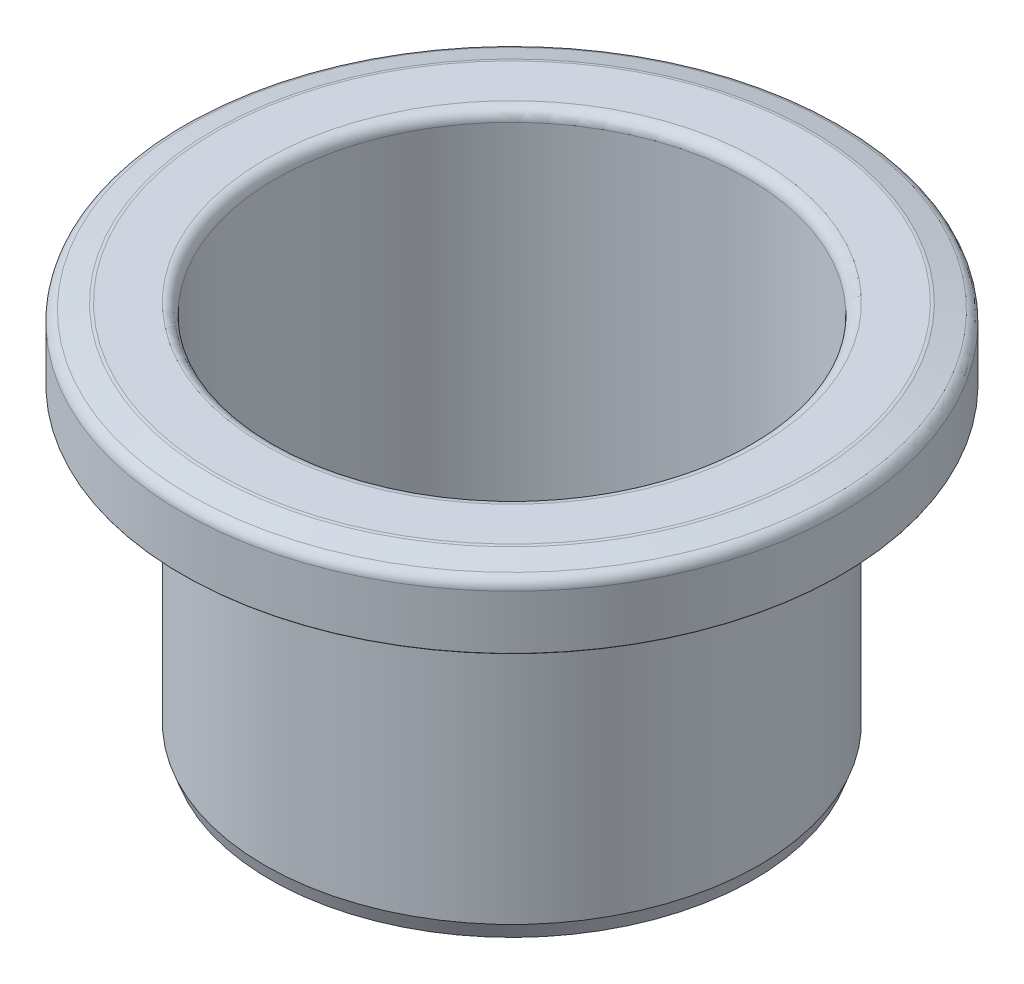
from build123d import *

# Parameters (mm, degrees)
SPESSORE1_T1  = 0.5
SPESSORE1_T2  = 0.5
RACCORDO1_R   = 0.05
RACCORDO2_R   = 1
SMUSSO1_SIZE  = 1.37373871
SMUSSO1_SIZE2 = 0.5


with BuildPart() as body_1:
    # Superficie-Rivoluzione2: a surface, the sketch's curves turned about an axis
    with BuildLine(Plane.XY, mode=Mode.PRIVATE) as superficie_rivoluzione2_1_path:
        Line((22, -2), (22, 32))
        Line((22, 32), (27, 32))
        Line((27, 32), (29.5, 31.330127019))
        Line((29.5, 31.330127019), (29.5, 26))
    superficie_rivoluzione2_1 = Shell.revolve(superficie_rivoluzione2_1_path.wire(), 360, Axis((0, -2, 0), (0, 1, 0)))
    add(Solid.thicken(superficie_rivoluzione2_1, SPESSORE1_T1))
    add(Solid.thicken(superficie_rivoluzione2_1, -SPESSORE1_T2))

    # Raccordo1
    raccordo1_edges = [body_1.edges().sort_by_distance(p)[0] for p in [
        (-29, 26, 0),
        (-30, 26, 0),
        (-21.5, -2, 0),
    ]]
    fillet(raccordo1_edges, radius=RACCORDO1_R)

    # Raccordo2
    raccordo2_edges = [body_1.edges().sort_by_distance(p)[0] for p in [
        (-22.5, 31.5, 0),
        (-26.934173751, 31.5, 0),
        (-29, 30.946463525, 0),
        (-30, 31.713790513, 0),
        (-27.065826249, 32.5, 0),
        (-21.5, 32.5, 0),
    ]]
    fillet(raccordo2_edges, radius=RACCORDO2_R)

    # Smusso1
    smusso1_edges = [body_1.edges().sort_by_distance(p)[0] for p in [
        (-22.5, -2, 0),
    ]]
    smusso1_side = [body_1.faces().sort_by_distance(p)[0] for p in [
        (-22.5, 14.25, 0),
    ]]
    chamfer(smusso1_edges, length=SMUSSO1_SIZE, length2=SMUSSO1_SIZE2, reference=smusso1_side[0])


solid = body_1.part
